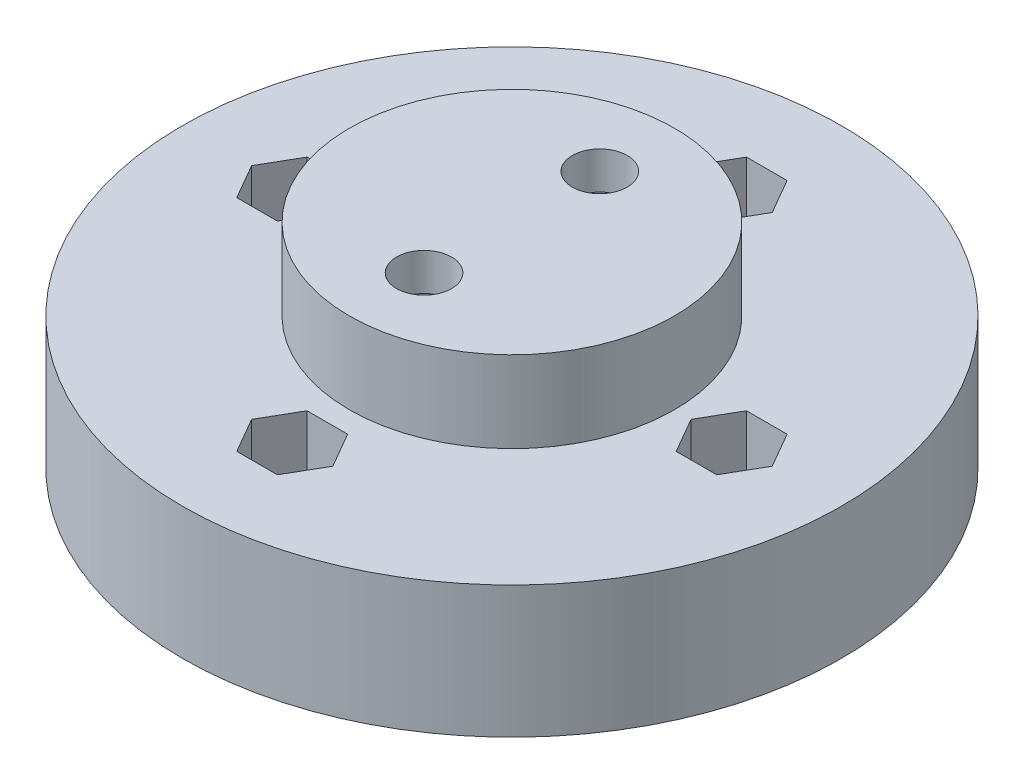
from build123d import *

# Parameters (mm, degrees)
SKETCH1_R           = 19.05
BOSS_EXTRUDE1_DEPTH = 7.62
SKETCH2_R           = 9.398
BOSS_EXTRUDE2_DEPTH = 4.699
SKETCH7_R           = 2.921
CUT_EXTRUDE5_DEPTH  = 10.16
SKETCH12_R          = 1.5875
CUT_EXTRUDE6_DEPTH  = 3.159
CUT_EXTRUDE7_DEPTH  = 5.08
SKETCH14_R          = 1.27
CUT_EXTRUDE8_DEPTH  = 8.62


with BuildPart() as part:
    # Sketch1 → Boss-Extrude1 (new body)
    with BuildSketch(Plane(origin=(0, 0, 0), x_dir=(1, 0, 0), z_dir=(0, 1, 0))):
        Circle(SKETCH1_R)
    extrude(amount=BOSS_EXTRUDE1_DEPTH)

    # Sketch2 → Boss-Extrude2 (add)
    with BuildSketch(Plane(origin=(0, 7.62, 0), x_dir=(1, 0, 0), z_dir=(0, 1, 0))):
        Circle(SKETCH2_R)
    extrude(amount=BOSS_EXTRUDE2_DEPTH)

    # Sketch7 → Cut-Extrude5 (cut)
    with BuildSketch(Plane.XZ):
        with Locations((0, 5.08)):
            Circle(SKETCH7_R)
        with Locations((0, -5.08)):
            Circle(SKETCH7_R)
    extrude(amount=-CUT_EXTRUDE5_DEPTH, mode=Mode.SUBTRACT)

    # Sketch12 → Cut-Extrude6 (cut, through all)
    with BuildSketch(Plane.XZ.offset(-10.16)):
        with Locations((0, 5.08)):
            Circle(SKETCH12_R)
        with Locations((0, -5.08)):
            Circle(SKETCH12_R)
    extrude(amount=-CUT_EXTRUDE6_DEPTH, mode=Mode.SUBTRACT)

    # Sketch13 → Cut-Extrude7 (cut)
    with BuildSketch(Plane(origin=(0, 7.62, 0), x_dir=(1, 0, 0), z_dir=(0, 1, 0))):
        Polygon((2.346351494, 12.7), (1.173175747, 14.732), (-1.173175747, 14.732), (-2.346351494, 12.7), (-1.173175747, 10.668), (1.173175747, 10.668), align=None)
        Polygon((2.346351494, -12.7), (1.173175747, -10.668), (-1.173175747, -10.668), (-2.346351494, -12.7), (-1.173175747, -14.732), (1.173175747, -14.732), align=None)
        Polygon((15.046351494, 0), (13.873175747, 2.032), (11.526824253, 2.032), (10.353648506, 0), (11.526824253, -2.032), (13.873175747, -2.032), align=None)
        Polygon((-10.353648506, 0), (-11.526824253, 2.032), (-13.873175747, 2.032), (-15.046351494, 0), (-13.873175747, -2.032), (-11.526824253, -2.032), align=None)
    extrude(amount=-CUT_EXTRUDE7_DEPTH, mode=Mode.SUBTRACT)

    # Sketch14 → Cut-Extrude8 (cut, through all)
    with BuildSketch(Plane(origin=(0, 7.62, 0), x_dir=(1, 0, 0), z_dir=(0, 1, 0))):
        with Locations((0, 12.7)):
            Circle(SKETCH14_R)
        with Locations((12.7, 0)):
            Circle(SKETCH14_R)
        with Locations((0, -12.7)):
            Circle(SKETCH14_R)
        with Locations((-12.7, 0)):
            Circle(SKETCH14_R)
    extrude(amount=-CUT_EXTRUDE8_DEPTH, mode=Mode.SUBTRACT)


solid = part.part
